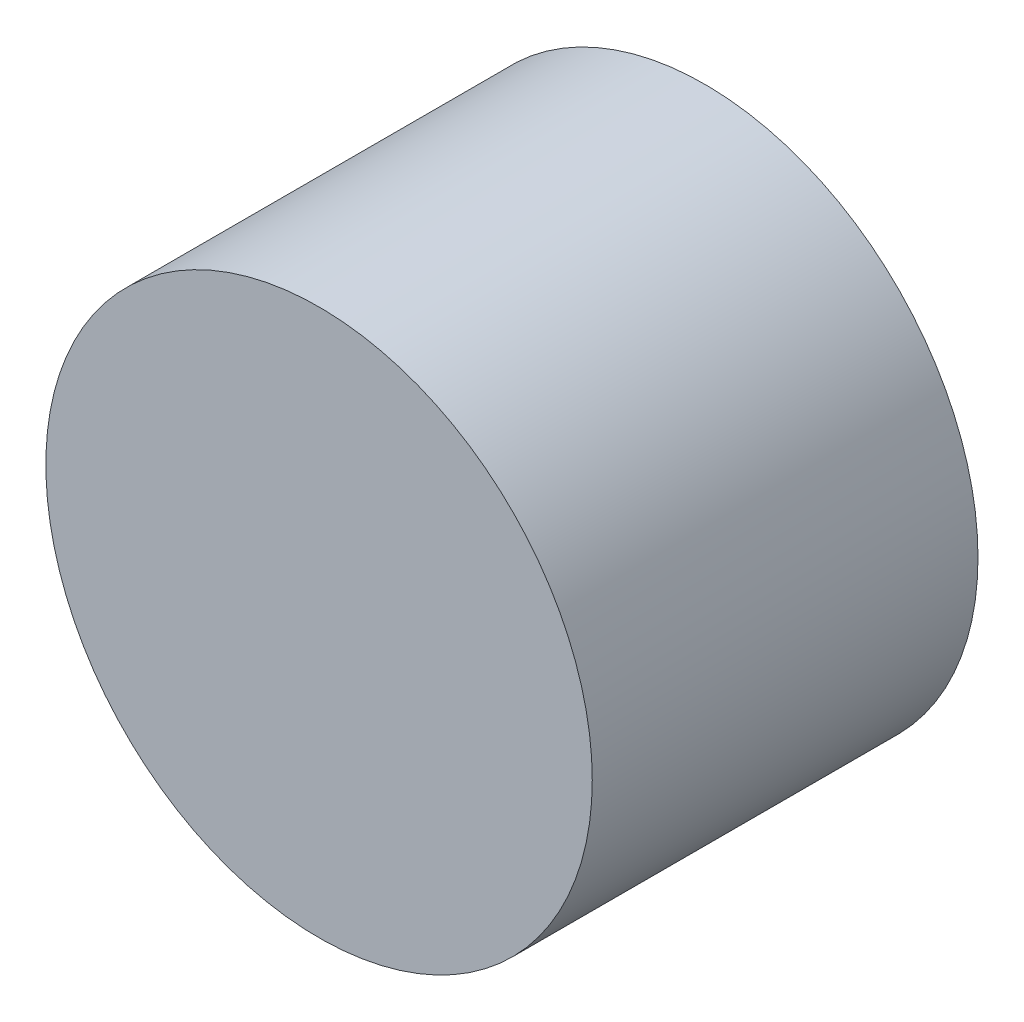
from build123d import *

# Parameters (mm, degrees)
SKETCH1_R           = 8.5
BOSS_EXTRUDE1_DEPTH = 12


with BuildPart() as part:
    # Sketch1 → Boss-Extrude1 (new body)
    with BuildSketch(Plane.XY):
        Circle(SKETCH1_R)
    extrude(amount=BOSS_EXTRUDE1_DEPTH)


solid = part.part
